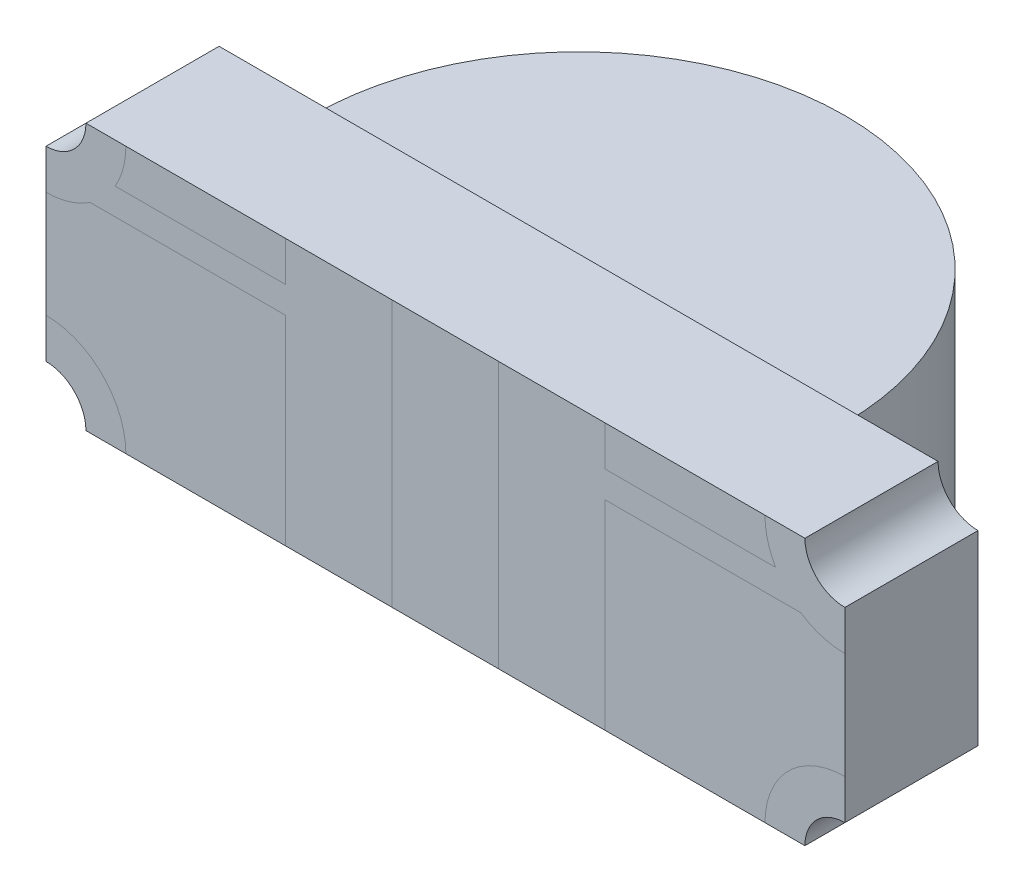
from build123d import *

# Parameters (mm, degrees)
BOSS_EXTRUDE1_DEPTH = 1
SKETCH2_R           = 0.15
CUT_EXTRUDE1_DEPTH  = 2.5
CUT_EXTRUDE2_DEPTH  = 0.05


with BuildPart() as part:
    # Sketch1 → Boss-Extrude1 (new body)
    with BuildSketch(Plane(origin=(0, 0, 0), x_dir=(1, 0, 0), z_dir=(0, 1, 0))):
        with BuildLine():
            Line((1, 0.5), (1.5, 0.5))
            Line((1.5, 0.5), (1.5, 0))
            Line((1.5, 0), (-1.5, 0))
            Line((-1.5, 0), (-1.5, 0.5))
            Line((-1.5, 0.5), (-1, 0.5))
            ThreePointArc((-1, 0.5), (0, 1.5), (1, 0.5))
        make_face()
    extrude(amount=BOSS_EXTRUDE1_DEPTH)

    # Sketch2 → Cut-Extrude1 (cut, through all)
    with BuildSketch(Plane.XY):
        with Locations((1.5, 1)):
            Circle(SKETCH2_R)
        with Locations((1.5, 0)):
            Circle(SKETCH2_R)
        with Locations((-1.5, 1)):
            Circle(SKETCH2_R)
        with Locations((-1.5, 0)):
            Circle(SKETCH2_R)
    extrude(amount=-CUT_EXTRUDE1_DEPTH, mode=Mode.SUBTRACT)

    # Sketch4 → Cut-Extrude2 (cut)
    with BuildSketch(Plane(origin=(0, 1, 0), x_dir=(1, 0, 0), z_dir=(0, 1, 0))):
        with BuildLine():
            Line((1, 0.5), (-1, 0.5))
            ThreePointArc((-1, 0.5), (0, 1.5), (1, 0.5))
        make_face()
    extrude(amount=-CUT_EXTRUDE2_DEPTH, mode=Mode.SUBTRACT)


solid = part.part
